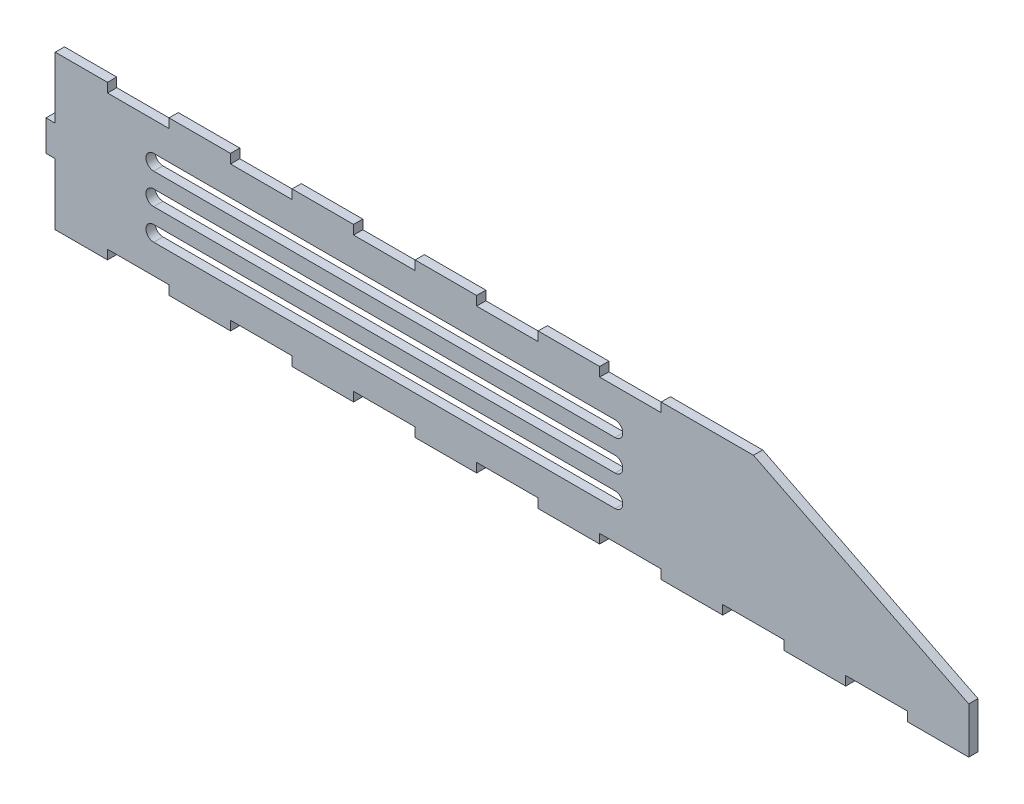
from build123d import *

# Parameters (mm, degrees)
BOSS_EXTRUDE1_DEPTH = 3
SKETCH2_W           = 20
SKETCH2_H           = 3
SKETCH2_W_2         = 3
SKETCH2_H_2         = 10
CUT_EXTRUDE1_DEPTH  = 3
SKETCH3_W           = 3
SKETCH3_H           = 10
CUT_EXTRUDE2_DEPTH  = 3
CUT_EXTRUDE3_DEPTH  = 3


with BuildPart() as part:
    # Sketch1 → Boss-Extrude1 (new body)
    with BuildSketch(Plane.XY):
        Polygon((80, 25), (150, -10), (150, -25), (-150, -25), (-150, 25), align=None)
    extrude(amount=BOSS_EXTRUDE1_DEPTH)

    # Sketch2 → Cut-Extrude1 (cut)
    with BuildSketch(Plane.XY.offset(3)):
        with Locations((-120, 23.5)):
            Rectangle(SKETCH2_W, SKETCH2_H)
        with Locations((-80, 23.5)):
            Rectangle(SKETCH2_W, SKETCH2_H)
        with Locations((-40, 23.5)):
            Rectangle(SKETCH2_W, SKETCH2_H)
        with Locations((-148.5, 10)):
            Rectangle(SKETCH2_W_2, SKETCH2_H_2)
        with Locations((-120, -23.5)):
            Rectangle(SKETCH2_W, SKETCH2_H)
        with Locations((0, 23.5)):
            Rectangle(SKETCH2_W, SKETCH2_H)
        with Locations((40, 23.5)):
            Rectangle(SKETCH2_W, SKETCH2_H)
        with Locations((-80, -23.5)):
            Rectangle(SKETCH2_W, SKETCH2_H)
        with Locations((-40, -23.5)):
            Rectangle(SKETCH2_W, SKETCH2_H)
        with Locations((0, -23.5)):
            Rectangle(SKETCH2_W, SKETCH2_H)
        with Locations((40, -23.5)):
            Rectangle(SKETCH2_W, SKETCH2_H)
        with Locations((80, -23.5)):
            Rectangle(SKETCH2_W, SKETCH2_H)
        with Locations((120, -23.5)):
            Rectangle(SKETCH2_W, SKETCH2_H)
        with Locations((-148.5, -10)):
            Rectangle(SKETCH2_W_2, SKETCH2_H_2)
    extrude(amount=-CUT_EXTRUDE1_DEPTH, mode=Mode.SUBTRACT)

    # Sketch3 → Cut-Extrude2 (cut)
    with BuildSketch(Plane.XY.offset(3)):
        with Locations((-148.5, 20)):
            Rectangle(SKETCH3_W, SKETCH3_H)
        with Locations((-148.5, -20)):
            Rectangle(SKETCH3_W, SKETCH3_H)
    extrude(amount=-CUT_EXTRUDE2_DEPTH, mode=Mode.SUBTRACT)

    # Sketch4 → Cut-Extrude3 (cut)
    with BuildSketch(Plane.XY.offset(3)):
        with BuildLine():
            Line((35, 7.5), (-115, 7.5))
            ThreePointArc((-115, 7.5), (-117.5, 10), (-115, 12.5))
            Line((-115, 12.5), (35, 12.5))
            ThreePointArc((35, 12.5), (37.5, 10), (35, 7.5))
        make_face()
        with BuildLine():
            Line((35, -2.5), (-115, -2.5))
            ThreePointArc((-115, -2.5), (-117.5, 0), (-115, 2.5))
            Line((-115, 2.5), (35, 2.5))
            ThreePointArc((35, 2.5), (37.5, 0), (35, -2.5))
        make_face()
        with BuildLine():
            Line((35, -12.5), (-115, -12.5))
            ThreePointArc((-115, -12.5), (-117.5, -10), (-115, -7.5))
            Line((-115, -7.5), (35, -7.5))
            ThreePointArc((35, -7.5), (37.5, -10), (35, -12.5))
        make_face()
    extrude(amount=-CUT_EXTRUDE3_DEPTH, mode=Mode.SUBTRACT)


solid = part.part
